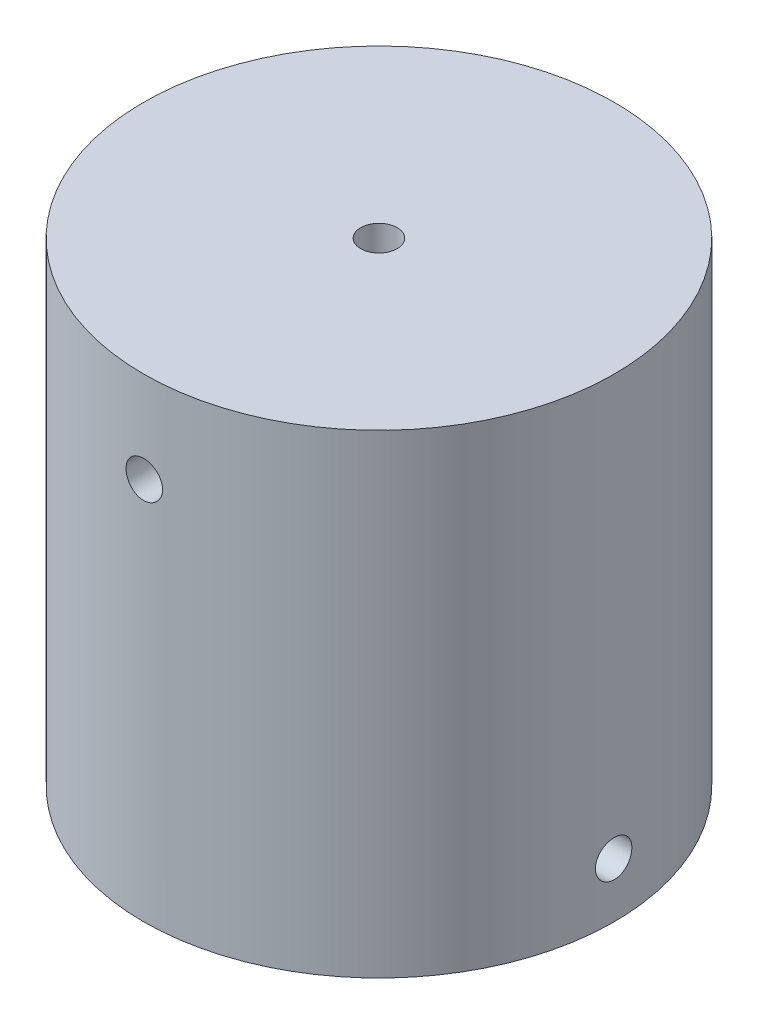
from build123d import *

# Parameters (mm, degrees)
SKETCH1_R               = 12.9
BOSS_EXTRUDE1_DEPTH     = 6
SKETCH2_R               = 12.9
BOSS_EXTRUDE2_DEPTH     = 20
SKETCH3_R               = 1
CUT_EXTRUDE2_DEPTH      = 5
SKETCH4_R               = 1
CUT_EXTRUDE3_DEPTH      = 18
CUT_EXTRUDE3_DEPTH_BACK = 19
CUT_EXTRUDE4_DEPTH      = 19
CUT_EXTRUDE4_DEPTH_BACK = 19
BOSS_EXTRUDE3_DEPTH     = 6
SKETCH7_R               = 1
CUT_EXTRUDE5_DEPTH      = 10


with BuildPart() as part:
    # Sketch1 → Boss-Extrude1 (new body)
    with BuildSketch(Plane(origin=(0, 0, 0), x_dir=(1, 0, 0), z_dir=(0, 1, 0))):
        with Locations((-0.136395343, 0.136395343)):
            Circle(SKETCH1_R)
        with BuildLine():
            Line((-2.036395343, -1.607164235), (-2.036395343, -2.054494887))
            ThreePointArc((-2.036395343, -2.054494887), (-1.150401835, -2.580549786), (-0.136395343, -2.763604657))
            ThreePointArc((-0.136395343, -2.763604657), (0.877611149, -2.580549786), (1.763604657, -2.054494887))
            Line((1.763604657, -2.054494887), (1.763604657, -1.607164235))
            Line((1.763604657, -1.607164235), (1.763604657, 1.87995492))
            Line((1.763604657, 1.87995492), (1.763604657, 2.327285573))
            ThreePointArc((1.763604657, 2.327285573), (0.877611149, 2.853340472), (-0.136395343, 3.036395343))
            ThreePointArc((-0.136395343, 3.036395343), (-1.150401835, 2.853340472), (-2.036395343, 2.327285573))
            Line((-2.036395343, 2.327285573), (-2.036395343, 1.87995492))
            Line((-2.036395343, 1.87995492), (-2.036395343, -1.607164235))
        make_face(mode=Mode.SUBTRACT)
    extrude(amount=BOSS_EXTRUDE1_DEPTH)

    # Sketch2 → Boss-Extrude2 (add)
    with BuildSketch(Plane(origin=(0, 6, 0), x_dir=(1, 0, 0), z_dir=(0, 1, 0))):
        with Locations((-0.136395343, 0.136395343)):
            Circle(SKETCH2_R)
    extrude(amount=BOSS_EXTRUDE2_DEPTH)

    # Sketch3 → Cut-Extrude2 (cut)
    with BuildSketch(Plane(origin=(0, 26, 0), x_dir=(1, 0, 0), z_dir=(0, 1, 0))):
        with Locations((-0.136395343, 0.136395343)):
            Circle(SKETCH3_R)
    extrude(amount=-CUT_EXTRUDE2_DEPTH, mode=Mode.SUBTRACT)

    # Sketch4 → Cut-Extrude3 (cut, two sides)
    with BuildSketch(Plane(origin=(0, 0, 0), x_dir=(0, 0, -1), z_dir=(1, 0, 0))) as cut_extrude3_sk:
        with Locations((0.136395343, 3)):
            Circle(SKETCH4_R)
    extrude(amount=CUT_EXTRUDE3_DEPTH, mode=Mode.SUBTRACT)
    extrude(cut_extrude3_sk.sketch, amount=-CUT_EXTRUDE3_DEPTH_BACK, mode=Mode.SUBTRACT)

    # Sketch5 → Cut-Extrude4 (cut, two sides)
    with BuildSketch(Plane.XY) as cut_extrude4_sk:
        with BuildLine():
            ThreePointArc((-1.136395343, 21), (-0.136395343, 20), (0.863604657, 21))
            Line((0.863604657, 21), (-1.136395343, 21))
        make_face()
        with BuildLine():
            Line((-1.136395343, 21), (0.863604657, 21))
            ThreePointArc((0.863604657, 21), (-0.136395343, 22), (-1.136395343, 21))
        make_face()
        with BuildLine():
            ThreePointArc((-1.136395343, 21), (-0.136395343, 20), (0.863604657, 21))
            Line((0.863604657, 21), (-1.136395343, 21))
        make_face()
        with BuildLine():
            Line((-1.136395343, 21), (0.863604657, 21))
            ThreePointArc((0.863604657, 21), (-0.136395343, 22), (-1.136395343, 21))
        make_face()
    extrude(amount=CUT_EXTRUDE4_DEPTH, mode=Mode.SUBTRACT)
    extrude(cut_extrude4_sk.sketch, amount=-CUT_EXTRUDE4_DEPTH_BACK, mode=Mode.SUBTRACT)

    # Sketch6 → Boss-Extrude3 (add)
    with BuildSketch(Plane.XZ):
        with BuildLine():
            ThreePointArc((-2.036395343, 2.054494887), (-0.136395343, 2.763604657), (1.763604657, 2.054494887))
            Line((1.763604657, 2.054494887), (1.763604657, -2.327285573))
            ThreePointArc((1.763604657, -2.327285573), (-0.136395343, -3.036395343), (-2.036395343, -2.327285573))
            Line((-2.036395343, -2.327285573), (-2.036395343, 2.054494887))
        make_face()
        with BuildLine():
            ThreePointArc((-0.136395343, 2.563604657), (-1.038180301, 2.408557287), (-1.836395343, 1.961222353))
            Line((-1.836395343, 1.961222353), (-1.836395343, 1.607164235))
            Line((-1.836395343, 1.607164235), (-1.836395343, -1.87995492))
            Line((-1.836395343, -1.87995492), (-1.836395343, -2.234013039))
            ThreePointArc((-1.836395343, -2.234013039), (-1.038180301, -2.681347973), (-0.136395343, -2.836395343))
            ThreePointArc((-0.136395343, -2.836395343), (0.765389615, -2.681347973), (1.563604657, -2.234013039))
            Line((1.563604657, -2.234013039), (1.563604657, -1.87995492))
            Line((1.563604657, -1.87995492), (1.563604657, 1.607164235))
            Line((1.563604657, 1.607164235), (1.563604657, 1.961222353))
            ThreePointArc((1.563604657, 1.961222353), (0.765389615, 2.408557287), (-0.136395343, 2.563604657))
        make_face(mode=Mode.SUBTRACT)
    extrude(amount=-BOSS_EXTRUDE3_DEPTH)

    # Sketch7 → Cut-Extrude5 (cut)
    with BuildSketch(Plane(origin=(0, 26, 0), x_dir=(1, 0, 0), z_dir=(0, 1, 0))):
        with Locations((-0.136395343, 0.136395343)):
            Circle(SKETCH7_R)
        with Locations((-0.136395343, 0.136395343)):
            Circle(SKETCH7_R)
    extrude(amount=-CUT_EXTRUDE5_DEPTH, mode=Mode.SUBTRACT)


solid = part.part
